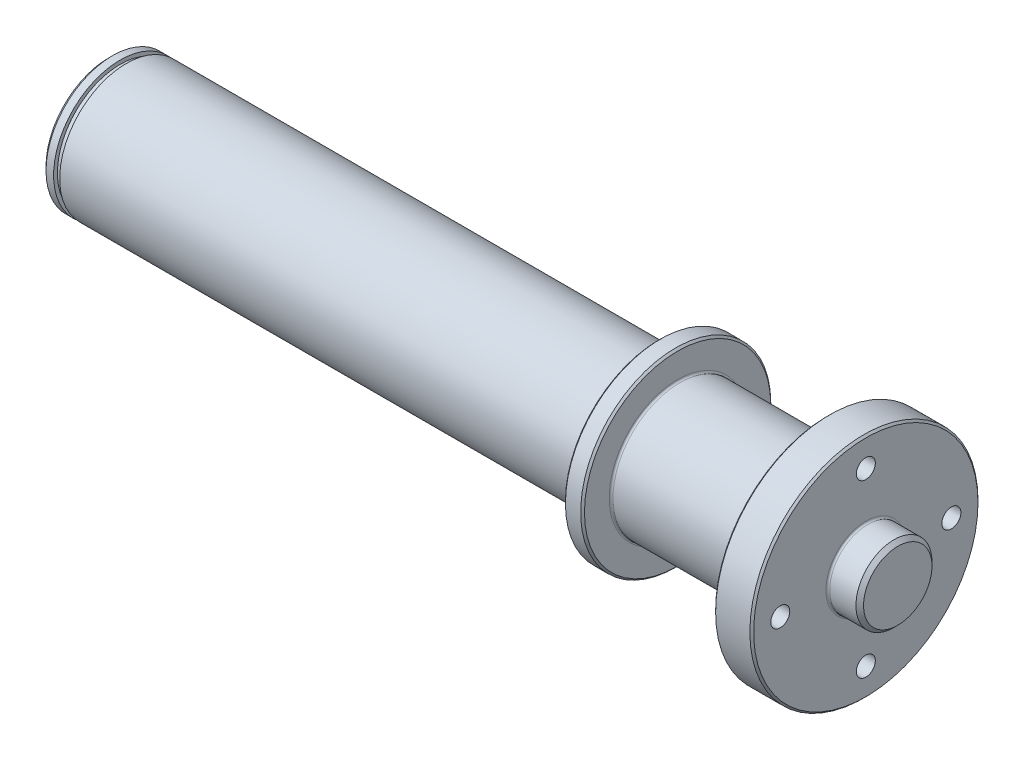
from build123d import *

# Parameters (mm, degrees)
OTW_R_GWINTOWANY_M63_D     = 5
OTW_R_GWINTOWANY_M63_DEPTH = 10
SFAZOWANIE1_SIZE           = 1
ZAOKR_GLENIE1_R            = 0.5
SFAZOWANIE2_SIZE           = 0.5
ZAOKR_GLENIE2_R            = 0.5
WYTNIJ_WYCI_GNI_CIE1_DEPTH = 5


with BuildPart() as part:
    # Szkic1 → Obrót1 (revolve)
    with BuildSketch(Plane.XY):
        Polygon((0, 0), (207.5, 0), (207.5, 10), (199.1, 10), (199.1, 30), (189.1, 30), (189.1, 17.5), (149.6, 17.5), (149.6, 25), (144.6, 25), (144.6, 17.5), (4.6, 17.5), (4.6, 16.5), (3, 16.5), (3, 17.5), (0, 17.5), align=None)
    revolve(axis=Axis((0, 0, 0), (-1, 0, 0)))

    # Otwór gwintowany M63
    with Locations(Plane(origin=(199.1, 0, 0), x_dir=(0, 0, -1), z_dir=(1, 0, 0))):
        with Locations((0, 22.5), (22.5, 0), (0, -22.5), (-22.5, 0)):
            Hole(OTW_R_GWINTOWANY_M63_D / 2, depth=OTW_R_GWINTOWANY_M63_DEPTH)

    # Sfazowanie1
    sfazowanie1_edges = [part.edges().sort_by_distance(p)[0] for p in [
        (207.5, -10, 0),
        (0, -17.5, 0),
    ]]
    chamfer(sfazowanie1_edges, length=SFAZOWANIE1_SIZE)

    # Zaokrąglenie1
    zaokr_glenie1_edges = [part.edges().sort_by_distance(p)[0] for p in [
        (189.1, -17.5, 0),
        (149.6, -17.5, 0),
        (144.6, -17.5, 0),
    ]]
    fillet(zaokr_glenie1_edges, radius=ZAOKR_GLENIE1_R)

    # Sfazowanie2
    sfazowanie2_edges = [part.edges().sort_by_distance(p)[0] for p in [
        (199.1, -30, 0),
        (189.1, -30, 0),
        (149.6, -25, 0),
        (144.6, -25, 0),
    ]]
    chamfer(sfazowanie2_edges, length=SFAZOWANIE2_SIZE)

    # Zaokrąglenie2
    zaokr_glenie2_edges = [part.edges().sort_by_distance(p)[0] for p in [
        (199.1, -10, 0),
    ]]
    fillet(zaokr_glenie2_edges, radius=ZAOKR_GLENIE2_R)

    # Szkic7 → Wytnij-wyciągnięcie1 (cut)
    with BuildSketch(Plane(origin=(0, 0, -17.5), x_dir=(-1, 0, 0), z_dir=(0, 0, -1))):
        with BuildLine():
            Line((-12.1, -5), (-42.1, -5))
            ThreePointArc((-42.1, -5), (-47.1, 0), (-42.1, 5))
            Line((-42.1, 5), (-12.1, 5))
            ThreePointArc((-12.1, 5), (-7.1, 0), (-12.1, -5))
        make_face()
    extrude(amount=-WYTNIJ_WYCI_GNI_CIE1_DEPTH, mode=Mode.SUBTRACT)


solid = part.part
